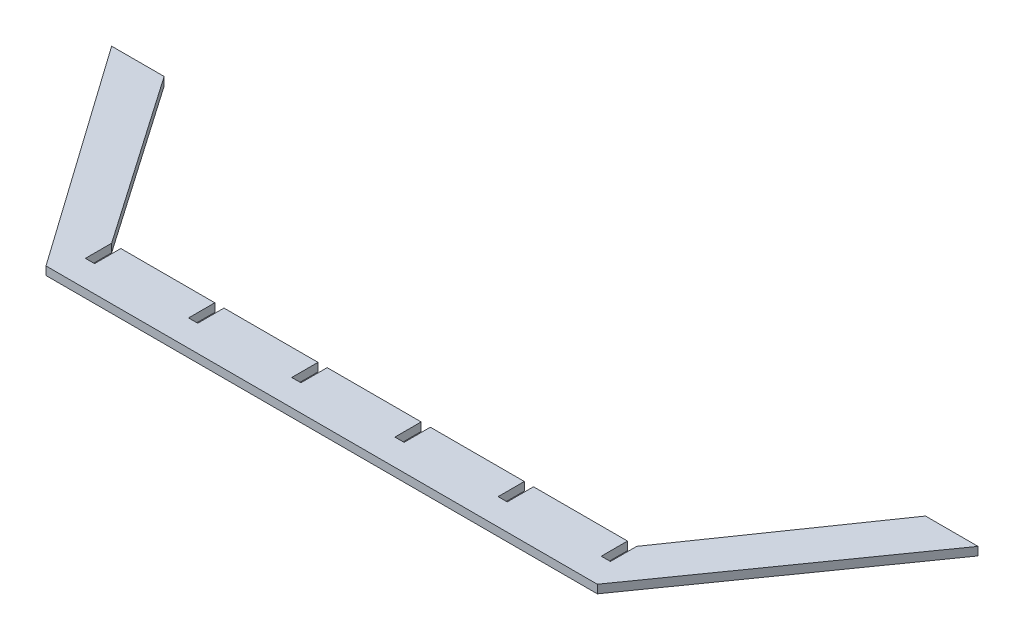
from build123d import *

# Parameters (mm, degrees)
BOSS_EXTRUDE1_DEPTH = 3.175
SKETCH3_W           = 3.5
SKETCH3_H           = 10
CUT_EXTRUDE1_DEPTH  = 4.175


with BuildPart() as part:
    # Sketch2 → Boss-Extrude1 (new body)
    with BuildSketch(Plane(origin=(0, 0, 0), x_dir=(1, 0, 0), z_dir=(0, 1, 0))):
        Polygon((0, 0), (-5, 0), (-65, 85), (-45, 85), (0, 20), (200, 20), (245, 85), (265, 85), (205, 0), (200, 0), align=None)
    extrude(amount=BOSS_EXTRUDE1_DEPTH)

    # Sketch3 → Cut-Extrude1 (cut, through all)
    with BuildSketch(Plane(origin=(0, 3.175, 0), x_dir=(1, 0, 0), z_dir=(0, 1, 0))):
        with Locations((41.05, 15)):
            Rectangle(SKETCH3_W, SKETCH3_H)
        with Locations((1.75, 15)):
            Rectangle(SKETCH3_W, SKETCH3_H)
        with Locations((80.35, 15)):
            Rectangle(SKETCH3_W, SKETCH3_H)
        with Locations((119.65, 15)):
            Rectangle(SKETCH3_W, SKETCH3_H)
        with Locations((158.95, 15)):
            Rectangle(SKETCH3_W, SKETCH3_H)
        with Locations((198.25, 15)):
            Rectangle(SKETCH3_W, SKETCH3_H)
    extrude(amount=-CUT_EXTRUDE1_DEPTH, mode=Mode.SUBTRACT)


solid = part.part
